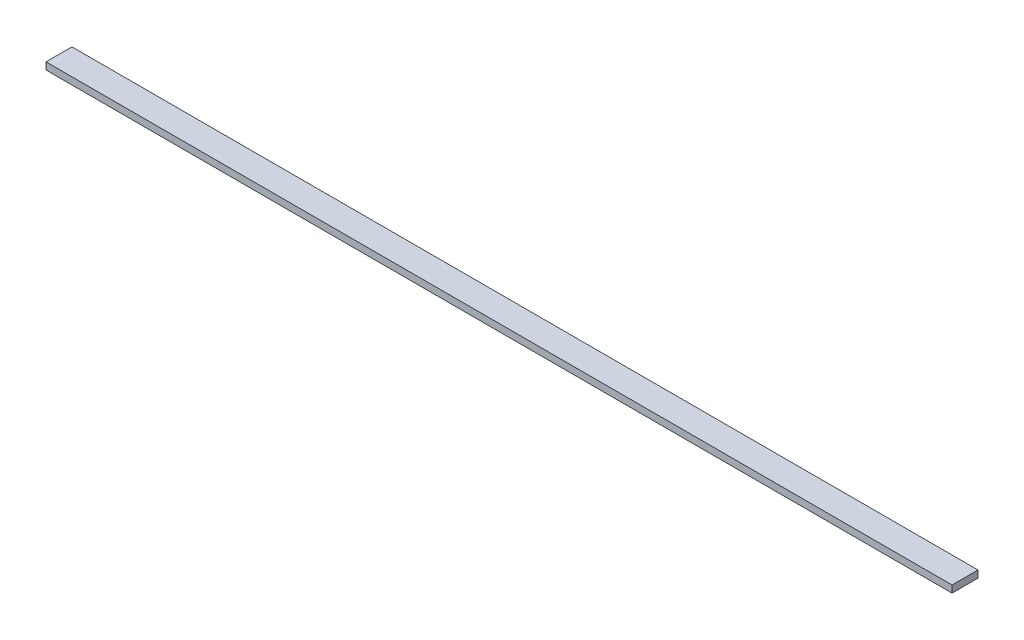
from build123d import *

# Parameters (mm, degrees)
SKETCH1_W           = 4876.8
SKETCH1_H           = 139.7
BOSS_EXTRUDE1_DEPTH = 38.1


with BuildPart() as part:
    # Sketch1 → Boss-Extrude1 (new body)
    with BuildSketch(Plane(origin=(0, 0, 0), x_dir=(1, 0, 0), z_dir=(0, 1, 0))):
        with Locations((2343.379633687, 69.85)):
            Rectangle(SKETCH1_W, SKETCH1_H)
    extrude(amount=BOSS_EXTRUDE1_DEPTH)


solid = part.part
